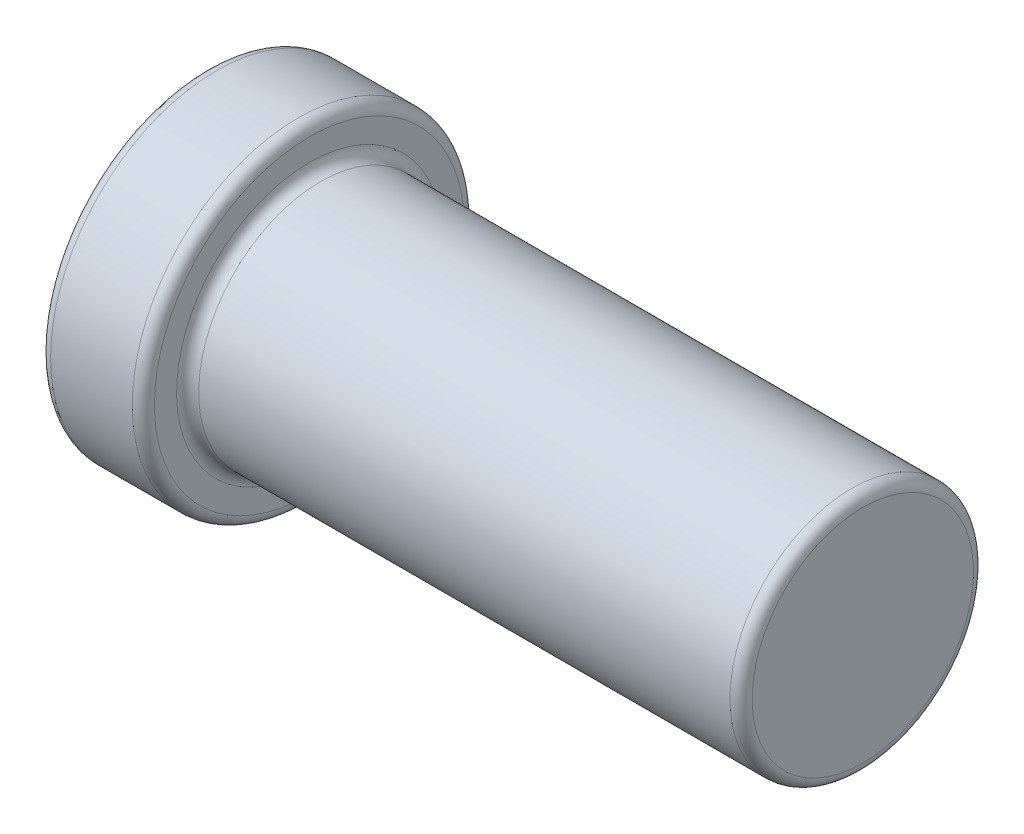
from build123d import *

# Parameters (mm, degrees)
FILLET1_R = 0.1
FILLET2_R = 0.1


with BuildPart() as part:
    # Sketch1 → Revolve1 (revolve)
    with BuildSketch(Plane.XY):
        Polygon((0, 1.5), (1, 1.5), (1, 1.1), (6, 1.1), (6, 0), (0.5, 0), (0.5, 0.5), align=None)
    revolve(axis=Axis((6, 0, 0), (-1, 0, 0)))

    # Fillet1
    fillet1_edges = [part.edges().sort_by_distance(p)[0] for p in [
        (6, -1.1, 0),
    ]]
    fillet(fillet1_edges, radius=FILLET1_R)

    # Fillet2
    fillet2_edges = [part.edges().sort_by_distance(p)[0] for p in [
        (0.5, -0.5, 0),
        (1, -1.1, 0),
        (1, -1.5, 0),
        (0, -1.5, 0),
    ]]
    fillet(fillet2_edges, radius=FILLET2_R)


solid = part.part
